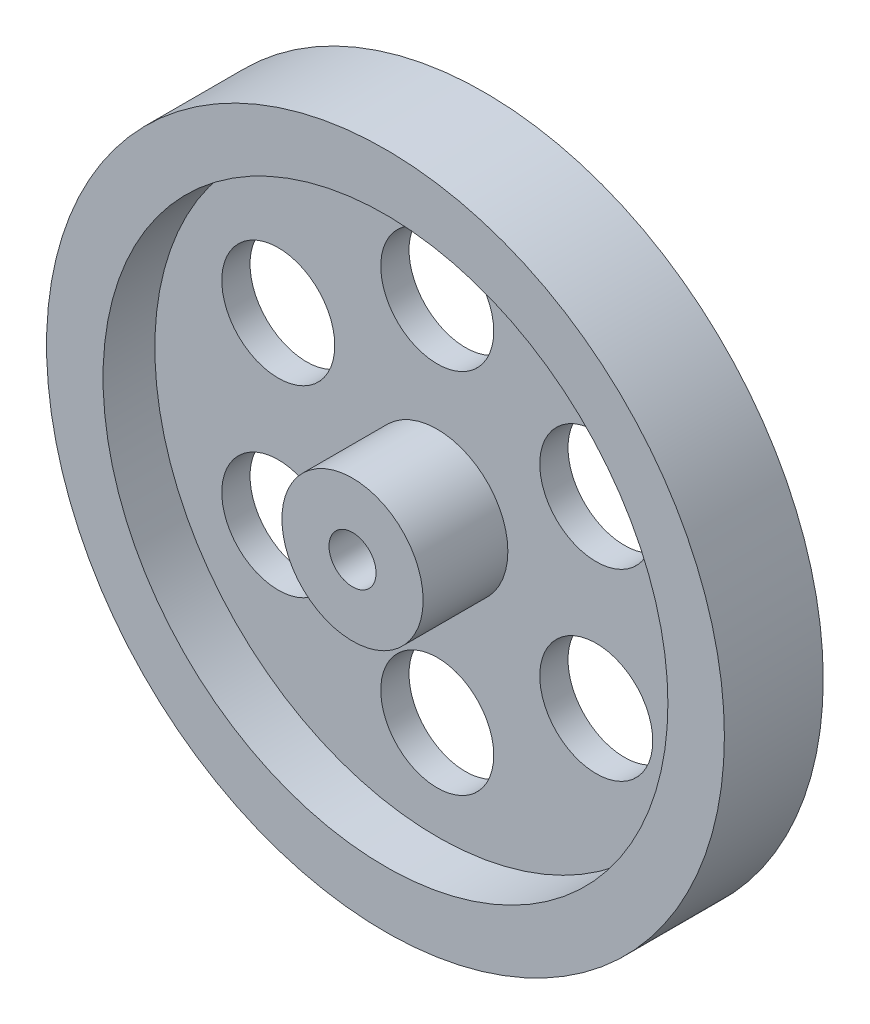
from build123d import *

# Parameters (mm, degrees)
ESQUISSE1_R             = 7.5
ESQUISSE1_R_2           = 2.5
BOSS_EXTRU_1_DEPTH      = 12
ESQUISSE1_3_R           = 30
ESQUISSE1_3_R_2         = 6
ESQUISSE1_3_R_3         = 7.5
BOSS_EXTRU_2_DEPTH      = 3
BOSS_EXTRU_3_DEPTH      = 8.5
BOSS_EXTRU_3_DEPTH_BACK = 2
ESQUISSE1_4_R           = 36
ESQUISSE1_4_R_2         = 30


with BuildPart() as part:
    # Esquisse1 → Boss.-Extru.1 (new body)
    with BuildSketch(Plane.XY):
        Circle(ESQUISSE1_R)
        Circle(ESQUISSE1_R_2, mode=Mode.SUBTRACT)
    extrude(amount=BOSS_EXTRU_1_DEPTH)

    # Esquisse1_3 → Boss.-Extru.2 (add)
    with BuildSketch(Plane.XY):
        Circle(ESQUISSE1_3_R)
        with Locations((-16.887495374, -9.75)):
            Circle(ESQUISSE1_3_R_2, mode=Mode.SUBTRACT)
        with Locations((0, -19.5)):
            Circle(ESQUISSE1_3_R_2, mode=Mode.SUBTRACT)
        with Locations((16.887495374, -9.75)):
            Circle(ESQUISSE1_3_R_2, mode=Mode.SUBTRACT)
        with Locations((-16.887495374, 9.75)):
            Circle(ESQUISSE1_3_R_2, mode=Mode.SUBTRACT)
        Circle(ESQUISSE1_3_R_3, mode=Mode.SUBTRACT)
        with Locations((16.887495374, 9.75)):
            Circle(ESQUISSE1_3_R_2, mode=Mode.SUBTRACT)
        with Locations((0, 19.5)):
            Circle(ESQUISSE1_3_R_2, mode=Mode.SUBTRACT)
    extrude(amount=BOSS_EXTRU_2_DEPTH)

    # Esquisse1_4 → Boss.-Extru.3 (add, two sides: drawn at the far end of the back side and taken through both)
    with BuildSketch(Plane.XY.offset(-BOSS_EXTRU_3_DEPTH_BACK)):
        Circle(ESQUISSE1_4_R)
        Circle(ESQUISSE1_4_R_2, mode=Mode.SUBTRACT)
    extrude(amount=BOSS_EXTRU_3_DEPTH + BOSS_EXTRU_3_DEPTH_BACK)


solid = part.part
